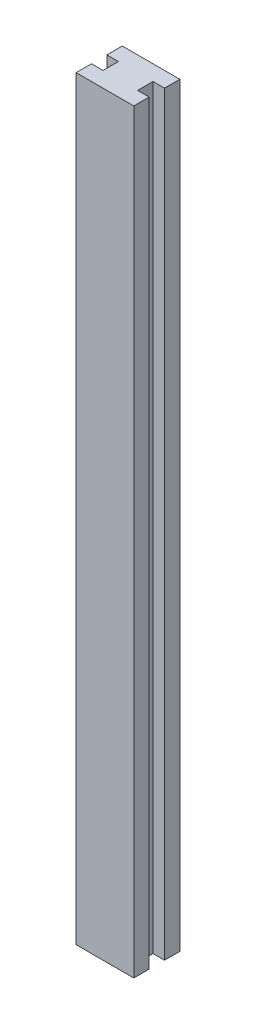
from build123d import *

# Parameters (mm, degrees)
BOSS_EXTRUDE1_DEPTH = 65.5


with BuildPart() as part:
    # Sketch1 → Boss-Extrude1 (new body)
    with BuildSketch(Plane(origin=(0, 0, 0), x_dir=(1, 0, 0), z_dir=(0, 1, 0))):
        Polygon((0, 0), (5, 0), (5, 1.333333333), (4, 1.333333333), (4, 2.666666667), (5, 2.666666667), (5, 4), (0, 4), (0, 2.666666667), (1, 2.666666667), (1, 1.333333333), (0, 1.333333333), align=None)
    extrude(amount=BOSS_EXTRUDE1_DEPTH)


solid = part.part
